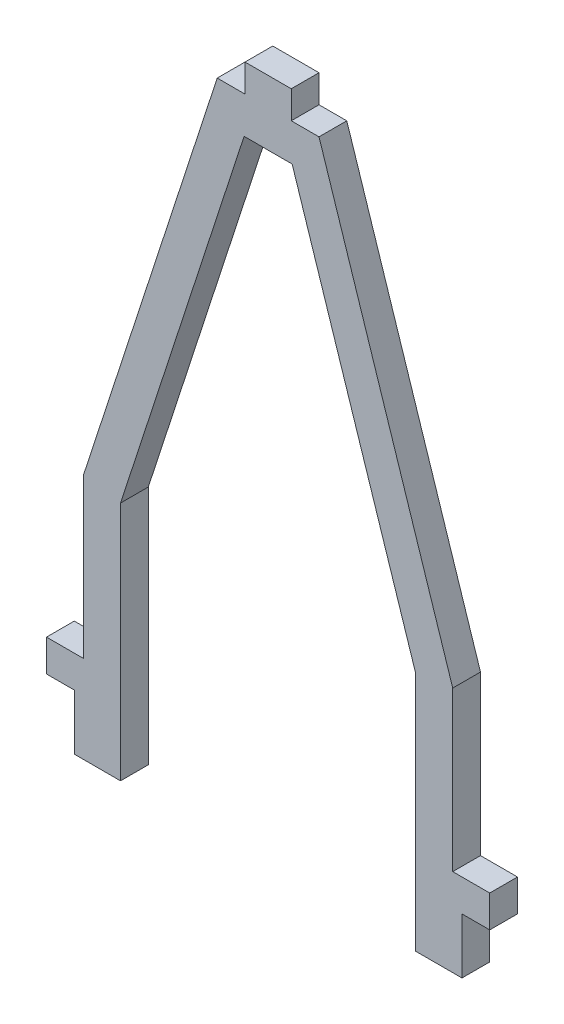
from build123d import *

# Parameters (mm, degrees)
BOSS_EXTRUDE1_DEPTH = 3


with BuildPart() as part:
    # Sketch1 → Boss-Extrude1 (new body)
    with BuildSketch(Plane.XY):
        Polygon((-6.383894407, -69.093441029), (-6.383894407, -43.093441029), (6.970100205, -2.093441029), (12.162110982, -2.093441029), (25.516105593, -43.093441029), (25.516105593, -69.093441029), (30.516105593, -69.093441029), (30.516105593, -63.093441029), (33.516105593, -63.093441029), (33.516105593, -59.638769888), (29.516105593, -59.638769888), (29.516105593, -42.458443205), (15.066105593, 1.906558971), (12.066105593, 1.906558971), (12.066105593, 4.906558971), (7.066105593, 4.906558971), (7.066105593, 1.906558971), (4.066105593, 1.906558971), (-10.383894407, -42.458443205), (-10.383894407, -59.638769888), (-14.383894407, -59.638769888), (-14.383894407, -63.093441029), (-11.383894407, -63.093441029), (-11.383894407, -69.093441029), align=None)
    extrude(amount=BOSS_EXTRUDE1_DEPTH)


solid = part.part
